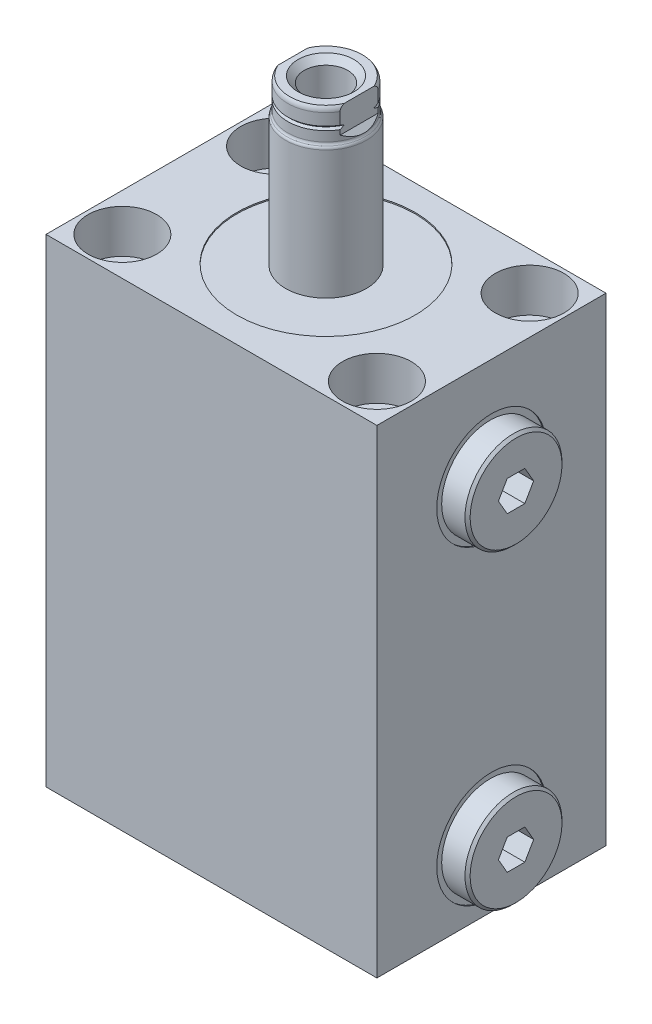
from build123d import *

# Parameters (mm, degrees)
SKETCH1_W                  = 65
SKETCH1_H                  = 45
EXTRUDE1_DEPTH             = 94
SKETCH2_R                  = 17.5
CUT_EXTRUDE1_DEPTH         = 0.254
CHAMFER1_SIZE              = 0.508
CUT_EXTRUDE2_DEPTH         = 5.9944
LPATTERN1_COUNT            = 2
LPATTERN1_PITCH            = 61
CHAMFER1_OF_LPATTERN1_SIZE = 0.508
SKETCH7_R                  = 0.889
LPATTERN2_COUNT            = 2
LPATTERN2_PITCH            = 25
CUT_EXTRUDE3_DEPTH         = 23.5
CUT_EXTRUDE3_DEPTH_BACK    = 23.5
HOLE1_D                    = 8.509
HOLE1_CBORE_D              = 13.487
HOLE1_CBORE_DEPTH          = 8.509


with BuildPart() as part:
    # Sketch1 → Extrude1 (new body)
    with BuildSketch(Plane(origin=(0, 0, 0), x_dir=(1, 0, 0), z_dir=(0, 1, 0))):
        Rectangle(SKETCH1_W, SKETCH1_H)
    extrude(amount=EXTRUDE1_DEPTH)

    # Sketch2 → Cut-Extrude1 (cut)
    with BuildSketch(Plane(origin=(0, 94, 0), x_dir=(1, 0, 0), z_dir=(0, 1, 0))):
        with Locations(Location((0, 0, 0), (0, 0, 270))):  # turned: the seam where the file's is
            Circle(SKETCH2_R)
    extrude(amount=-CUT_EXTRUDE1_DEPTH, mode=Mode.SUBTRACT)

    # Sketch3 → Cut-Revolve1 (revolve, cut)
    with BuildSketch(Plane.XY, mode=Mode.PRIVATE) as cut_revolve1_sk:
        Polygon((32.5, 74), (32.5, 63.256), (32.246, 63.256), (32.246, 67.3452), (31.5348, 68.0564), (16.752, 68.0564), (16.752, 74), align=None)
    cut_revolve1 = revolve(cut_revolve1_sk.sketch.rotate(Axis((-6.847979502, 74, 0), (1, 0, 0)), 270), axis=Axis((-6.847979502, 74, 0), (1, 0, 0)), mode=Mode.SUBTRACT)  # turned: the seam where the file's is

    # Sketch4 → Revolve1 (revolve)
    with BuildSketch(Plane.XY, mode=Mode.PRIVATE) as revolve1_sk:
        Polygon((20.308, 74), (20.308, 79.9182), (32.246, 79.9182), (32.246, 83.525), (37.326, 83.525), (37.326, 74), align=None)
    revolve1 = revolve(revolve1_sk.sketch.rotate(Axis((8.732572807, 74, 0), (1, 0, 0)), 90), axis=Axis((8.732572807, 74, 0), (1, 0, 0)))  # turned: the seam where the file's is

    # Chamfer1
    chamfer1_edges = [part.edges().sort_by_distance(p)[0] for p in [
        (37.326, 74, -9.525),
    ]]
    chamfer(chamfer1_edges, length=CHAMFER1_SIZE)

    # Sketch5 → Cut-Extrude2 (cut)
    with BuildSketch(Plane(origin=(37.326, 0, 0), x_dir=(0, 0, -1), z_dir=(1, 0, 0))):
        Polygon((1.730434227, 76.9972), (-1.730434227, 76.9972), (-3.460868454, 74), (-1.730434227, 71.0028), (1.730434227, 71.0028), (3.460868454, 74), align=None)
    cut_extrude2 = extrude(amount=-CUT_EXTRUDE2_DEPTH, mode=Mode.SUBTRACT)

    # LPattern1: Cut-Revolve1, Revolve1, Cut-Extrude2 ×2
    with Locations(*[(0, -i * LPATTERN1_PITCH, 0) for i in range(1, LPATTERN1_COUNT)]):
        add(cut_revolve1, mode=Mode.SUBTRACT)
        add(revolve1)
        add(cut_extrude2, mode=Mode.SUBTRACT)

    # Chamfer1 of LPattern1
    chamfer1_of_lpattern1_edges = [part.edges().sort_by_distance(p)[0] for p in [
        (37.326, 13, -9.525),
    ]]
    chamfer(chamfer1_of_lpattern1_edges, length=CHAMFER1_OF_LPATTERN1_SIZE)

    # Sketch6 → Cut-Revolve2 (revolve, cut)
    with BuildSketch(Plane.XY, mode=Mode.PRIVATE) as cut_revolve2_sk:
        Polygon((0, 0), (0, 14.895831126), (1.2446, 14.148), (1.2446, 4.9529), (1.7525, 4.445), (3.2512, 4.445), (3.2512, 1.448), (5.7025, 1.448), (5.7025, 0), align=None)
    cut_revolve2 = revolve(cut_revolve2_sk.sketch.rotate(Axis((0, 0, 0), (0, 1, 0)), 90), axis=Axis((0, 0, 0), (0, 1, 0)), mode=Mode.SUBTRACT)  # turned: the seam where the file's is

    # Sketch7 → Revolve3 (revolve)
    with BuildSketch(Plane.XY, mode=Mode.PRIVATE) as revolve3_sk:
        with Locations((4.814, 0.5844)):
            Circle(SKETCH7_R)
    revolve3 = revolve(revolve3_sk.sketch.rotate(Axis((0, 0, 0), (0, 1, 0)), 90), axis=Axis((0, 0, 0), (0, 1, 0)))  # turned: the seam where the file's is

    # LPattern2: Cut-Revolve2, Revolve3 ×2
    with Locations(*[(-i * LPATTERN2_PITCH, 0, 0) for i in range(1, LPATTERN2_COUNT)]):
        add(cut_revolve2, mode=Mode.SUBTRACT)
        add(revolve3)

    # Sketch8 → Revolve4 (revolve)
    with BuildSketch(Plane.XY, mode=Mode.PRIVATE) as revolve4_sk:
        with BuildLine():
            Line((7.925, 93.746), (7.925, 118.944170942))
            ThreePointArc((7.925, 118.944170942), (7.869881532, 119.228710043), (7.7125, 119.472085471))
            ThreePointArc((7.7125, 119.472085471), (7.555118468, 119.715460899), (7.5, 120))
            Line((7.5, 120), (7.5, 125.0094))
            ThreePointArc((7.5, 125.0094), (7.405612002, 125.537401443), (7.134139733, 126))
            Line((7.134139733, 126), (0, 126))
            Line((0, 126), (0, 93.746))
            Line((0, 93.746), (7.925, 93.746))
        make_face()
    revolve(revolve4_sk.sketch.rotate(Axis((0, 0, 0), (0, 1, 0)), 90), axis=Axis((0, 0, 0), (0, 1, 0)))  # turned: the seam where the file's is

    # Sketch10 → Cut-Revolve3 (revolve, cut)
    with BuildSketch(Plane.XY):
        Polygon((5.5, 126), (4.267, 124.767), (4.267, 105.68), (0, 103.116127739), (0, 126), align=None)
    revolve(axis=Axis((0, 126, 0), (0, -1, 0)), mode=Mode.SUBTRACT)

    # Sketch11 → Cut-Revolve4 (revolve, cut)
    with BuildSketch(Plane.XY, mode=Mode.PRIVATE) as cut_revolve4_sk:
        Polygon((7.5, 122.698), (7.119, 122.317), (7.5, 121.936), align=None)
    revolve(cut_revolve4_sk.sketch.rotate(Axis((0, 0, 0), (0, 1, 0)), 90), axis=Axis((0, 0, 0), (0, 1, 0)), mode=Mode.SUBTRACT)  # turned: the seam where the file's is

    # Sketch12 → Cut-Extrude3 (cut, two sides)
    with BuildSketch(Plane.XY) as cut_extrude3_sk:
        Polygon((6.5, 126), (6.5, 121), (7.925, 119.575), (7.925, 126), align=None)
        Polygon((-7.925, 126), (-6.5, 126), (-6.5, 121), (-7.925, 119.575), align=None)
    extrude(amount=CUT_EXTRUDE3_DEPTH, mode=Mode.SUBTRACT)
    extrude(cut_extrude3_sk.sketch, amount=-CUT_EXTRUDE3_DEPTH_BACK, mode=Mode.SUBTRACT)

    # Hole1 (through all)
    with Locations(Plane(origin=(0, 94, 0), x_dir=(-1, 0, 0), z_dir=(0, 1, 0))):
        with Locations((25, 15), (25, -15), (-25, -15), (-25, 15)):
            CounterBoreHole(HOLE1_D / 2, HOLE1_CBORE_D / 2, HOLE1_CBORE_DEPTH)


solid = part.part
